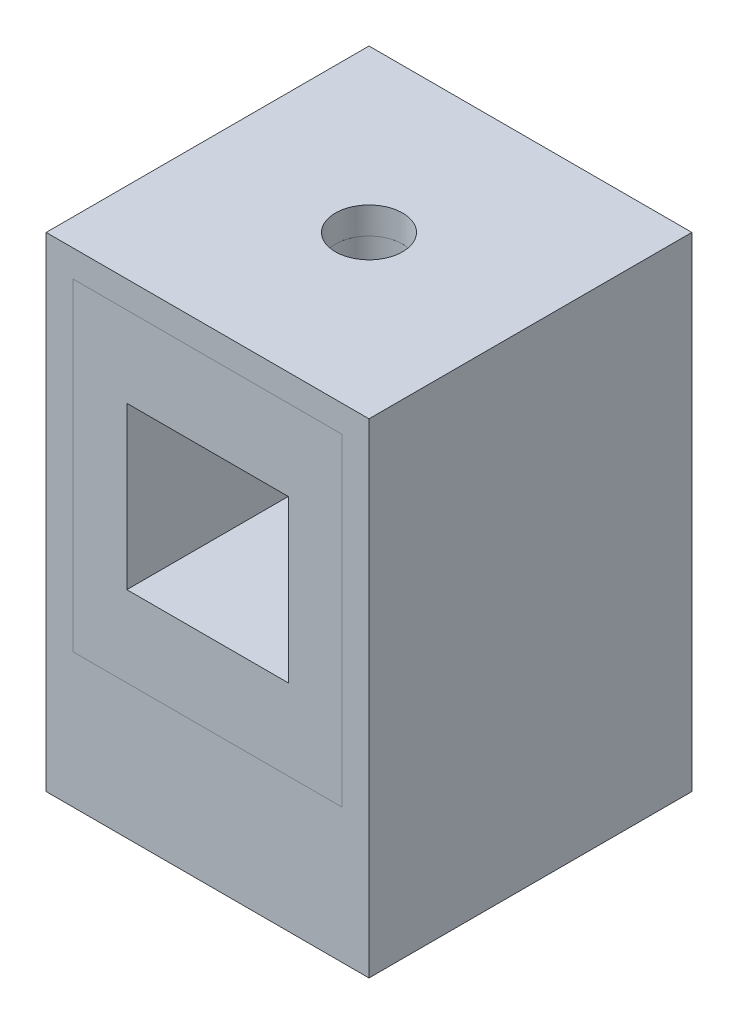
from build123d import *

# Parameters (mm, degrees)
SKETCH1_W      = 304.8
SKETCH1_H      = 304.8
EXTRUDE1_DEPTH = 457.2
SKETCH2_W      = 254
SKETCH2_H      = 304.8
EXTRUDE2_DEPTH = 279.4
EXTRUDE3_REACH = 306.8
SKETCH3_W      = 254
SKETCH3_H      = 304.8
SKETCH4_W      = 152.4
SKETCH4_H      = 152.4
EXTRUDE4_DEPTH = 254
SKETCH5_R      = 31.75
EXTRUDE5_DEPTH = 254


with BuildPart() as part:
    # Sketch1 → Extrude1 (new body)
    with BuildSketch(Plane(origin=(0, 0, 0), x_dir=(1, 0, 0), z_dir=(0, 1, 0))):
        Rectangle(SKETCH1_W, SKETCH1_H)
    extrude(amount=-EXTRUDE1_DEPTH)

    # Sketch2 → Extrude2 (cut)
    with BuildSketch(Plane.XY.offset(152.4)):
        with Locations((0, -177.8)):
            Rectangle(SKETCH2_W, SKETCH2_H)
    extrude(amount=-EXTRUDE2_DEPTH, mode=Mode.SUBTRACT)


with BuildPart() as body_2:

    # Sketch3 → Extrude3 (new body, up to next)
    with BuildSketch(Plane.XY.offset(152.4), mode=Mode.PRIVATE) as extrude3_sk1:
        with Locations((0, -177.8)):
            Rectangle(SKETCH3_W, SKETCH3_H)
    extrude3_tool1 = extrude(extrude3_sk1.sketch, amount=-EXTRUDE3_REACH, mode=Mode.PRIVATE) - part.part
    add(extrude3_tool1.solids().sort_by_distance((0, -177.8, 152.4))[0])

    # Sketch4 → Extrude4 (cut)
    with BuildSketch(Plane.XY.offset(152.4)):
        with Locations((0, -177.8)):
            Rectangle(SKETCH4_W, SKETCH4_H)
    extrude(amount=-EXTRUDE4_DEPTH, mode=Mode.SUBTRACT)


with BuildPart() as extrude5_tool:
    # Sketch5 → Extrude5 (new body)
    with BuildSketch(Plane(origin=(0, 0, 0), x_dir=(1, 0, 0), z_dir=(0, 1, 0))):
        Circle(SKETCH5_R)
    extrude(amount=-EXTRUDE5_DEPTH)


with BuildPart() as part_1:
    add(part.part)

    # Extrude5: cut by extrude5_tool
    add(extrude5_tool.part, mode=Mode.SUBTRACT)


with BuildPart() as body_2_1:
    add(body_2.part)

    # Extrude5: cut by extrude5_tool
    add(extrude5_tool.part, mode=Mode.SUBTRACT)


solid = Compound([part_1.part, body_2_1.part])
